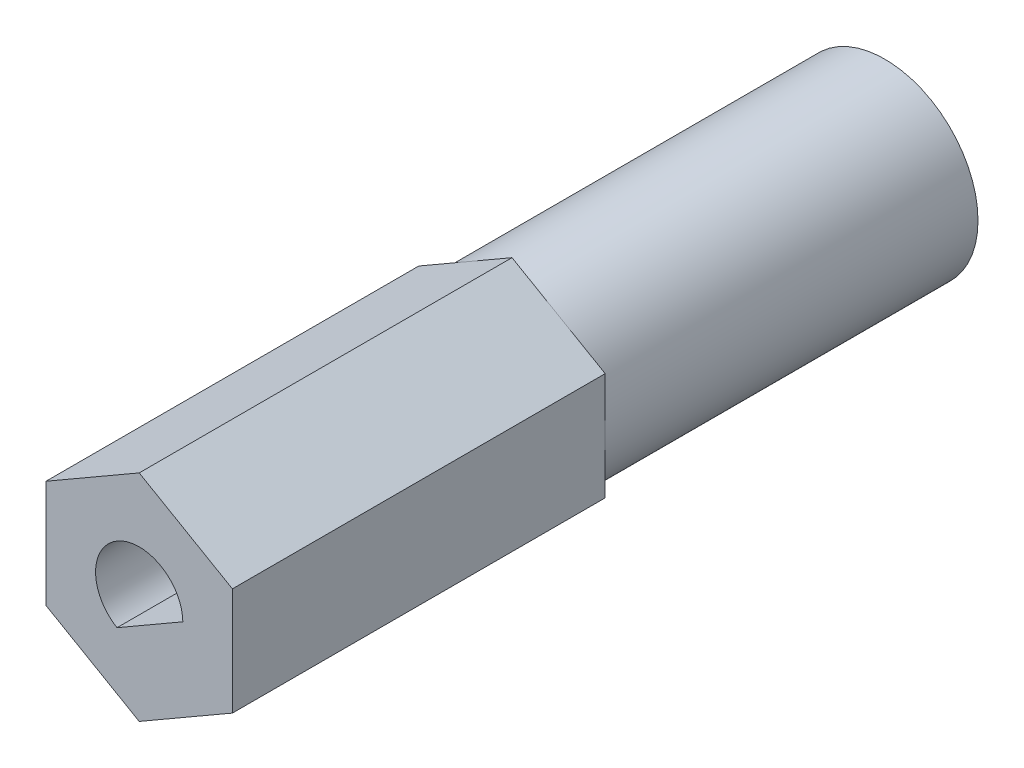
from build123d import *

# Parameters (mm, degrees)
BOSS_EXTRUDE1_DEPTH = 25.4
CUT_EXTRUDE1_DEPTH  = 5.08
SKETCH3_OUTSIDE_W   = 13.788
SKETCH3_OUTSIDE_H   = 14.77
SKETCH3_OUTSIDE_R   = 3.175
CUT_EXTRUDE2_DEPTH  = 13.7


with BuildPart() as part:
    # Sketch1 → Boss-Extrude1 (new body)
    with BuildSketch(Plane.XY):
        Polygon((0, 3.666174209), (-3.175, 1.833087105), (-3.175, -1.833087105), (0, -3.666174209), (3.175, -1.833087105), (3.175, 1.833087105), align=None)
    extrude(amount=-BOSS_EXTRUDE1_DEPTH)

    # Sketch2 → Cut-Extrude1 (cut)
    with BuildSketch(Plane.XY):
        with BuildLine():
            Line((-0.756832981, -1.278711324), (1.485812981, 0.016080926))
            ThreePointArc((1.485812981, 0.016080926), (-0.74295, 1.286827147), (-0.756832981, -1.278711324))
        make_face()
    extrude(amount=-CUT_EXTRUDE1_DEPTH, mode=Mode.SUBTRACT)

    # Sketch3 outside → Cut-Extrude2 (cut, through all)
    with BuildSketch(Plane.XY.offset(-12.7)):
        Rectangle(SKETCH3_OUTSIDE_W, SKETCH3_OUTSIDE_H)
        Circle(SKETCH3_OUTSIDE_R, mode=Mode.SUBTRACT)
    extrude(amount=-CUT_EXTRUDE2_DEPTH, mode=Mode.SUBTRACT)


solid = part.part
